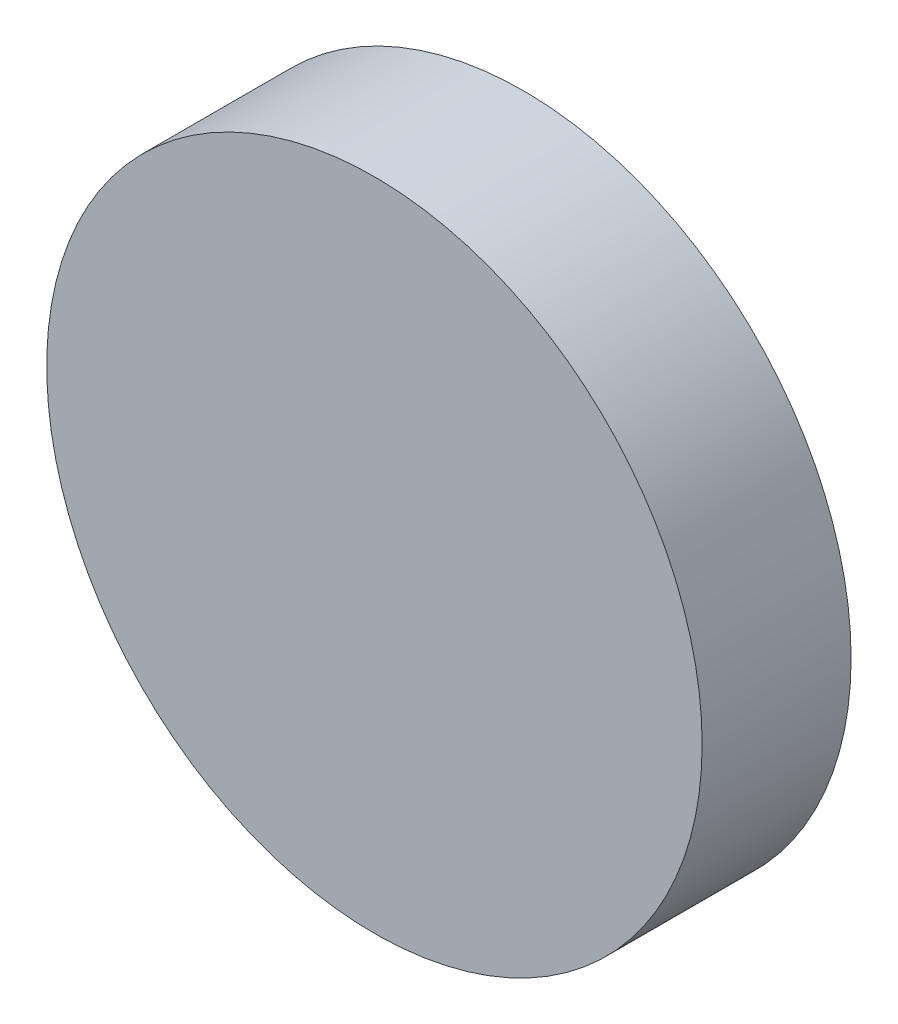
from build123d import *

# Parameters (mm, degrees)
SKETCH1_R           = 11
BOSS_EXTRUDE1_DEPTH = 5
SKETCH1_3_R         = 8.5
CUT_EXTRUDE1_DEPTH  = 3


with BuildPart() as part:
    # Sketch1 → Boss-Extrude1 (new body)
    with BuildSketch(Plane.XY):
        Circle(SKETCH1_R)
    extrude(amount=BOSS_EXTRUDE1_DEPTH)

    # Sketch1_3 → Cut-Extrude1 (cut)
    with BuildSketch(Plane.XY):
        Circle(SKETCH1_3_R)
    extrude(amount=CUT_EXTRUDE1_DEPTH, mode=Mode.SUBTRACT)


solid = part.part
